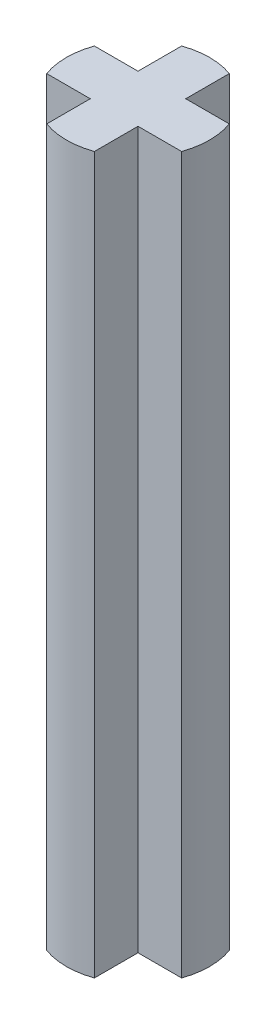
from build123d import *

# Parameters (mm, degrees)
SKETCH1_W           = 3
SKETCH1_H           = 1
SKETCH1_W_2         = 1
SKETCH1_H_2         = 3
BOSS_EXTRUDE1_DEPTH = 15
SKETCH2_OUTSIDE_W   = 8.118
SKETCH2_OUTSIDE_H   = 8.118
SKETCH2_OUTSIDE_R   = 1.5
CUT_EXTRUDE1_DEPTH  = 15


with BuildPart() as part:
    # Sketch1 → Boss-Extrude1 (new body)
    with BuildSketch(Plane(origin=(0, 0, 0), x_dir=(1, 0, 0), z_dir=(0, 1, 0))):
        Rectangle(SKETCH1_W, SKETCH1_H)
        Rectangle(SKETCH1_W_2, SKETCH1_H_2)
    extrude(amount=BOSS_EXTRUDE1_DEPTH)

    # Sketch2 outside → Cut-Extrude1 (cut)
    with BuildSketch(Plane(origin=(0, 15, 0), x_dir=(1, 0, 0), z_dir=(0, 1, 0))):
        Rectangle(SKETCH2_OUTSIDE_W, SKETCH2_OUTSIDE_H)
        Circle(SKETCH2_OUTSIDE_R, mode=Mode.SUBTRACT)
    extrude(amount=-CUT_EXTRUDE1_DEPTH, mode=Mode.SUBTRACT)


solid = part.part
